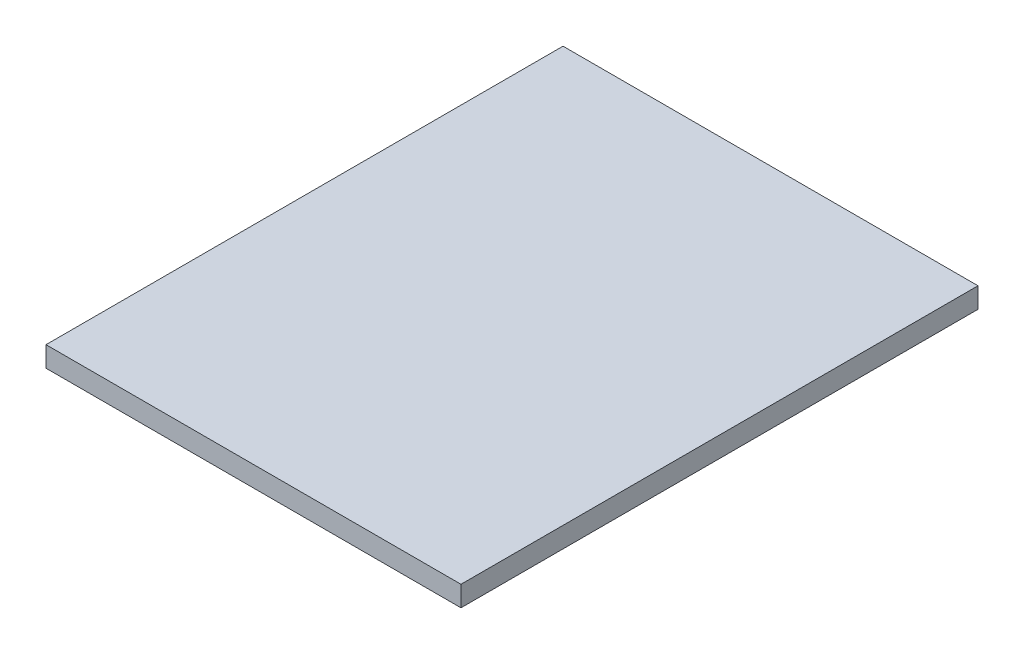
from build123d import *

# Parameters (mm, degrees)
SKETCH1_W           = 193.675
SKETCH1_H           = 241.3
BOSS_EXTRUDE1_DEPTH = 4.7625


with BuildPart() as part:
    # Sketch1 → Boss-Extrude1 (new body, symmetric)
    with BuildSketch(Plane(origin=(0, 0, 0), x_dir=(1, 0, 0), z_dir=(0, 1, 0))):
        Rectangle(SKETCH1_W, SKETCH1_H)
    extrude(amount=BOSS_EXTRUDE1_DEPTH, both=True)


solid = part.part
